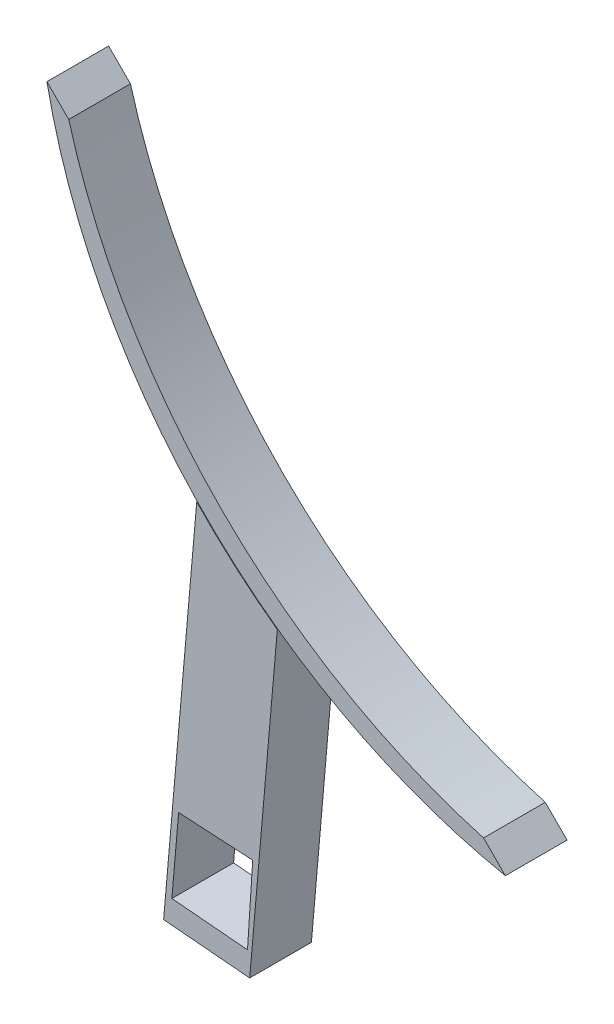
from build123d import *

# Parameters (mm, degrees)
BOSS_EXTRUDE1_DEPTH             = 10
SCALE1_SCALE                    = 0.5
BOSS_EXTRUDE2_REACH             = 46.064
BOSS_EXTRUDE2_END_RADIUS        = 47.489459432
SKETCH4_W                       = 5
SKETCH4_H                       = 7
BOSS_EXTRUDE2_DIRECTION_2_DEPTH = 20
CUT_EXTRUDE1_DEPTH              = 42.005284287


with BuildPart() as part:
    # Sketch1 → Boss-Extrude1 (new body)
    with BuildSketch(Plane.XY):
        with BuildLine():
            Line((40.984301278, -16.277292989), (37.448767372, -12.741759083))
            ThreePointArc((37.448767372, -12.741759083), (-4.964984169, 12.060025443), (-29.766768694, 54.473776984))
            Line((-29.766768694, 54.473776984), (-33.3023026, 58.00931089))
            ThreePointArc((-33.3023026, 58.00931089), (-7.365037029, 9.659972583), (40.984301278, -16.277292989))
        make_face()
    extrude(amount=BOSS_EXTRUDE1_DEPTH)


with BuildPart() as part_1:
    # Scale1: scaled about (-3.035293352, 13.98971626, 5)
    add(part.part.scale(SCALE1_SCALE).moved(Location((-1.517646676, 6.99485813, 2.5))))

    # Boss-Extrude2: up to this cylinder (the profile starts outside it)
    boss_extrude2_end = Plane(origin=(28.379953609, 45.404963221, 5.043467), z_dir=(0, 0, -1)) * Cylinder(BOSS_EXTRUDE2_END_RADIUS, 188.106918865, mode=Mode.PRIVATE)
    # Sketch4 → Boss-Extrude2 (add, up to the surface)
    with BuildSketch(Plane(origin=(7.010218182, 0.680511093, -0.258230649), x_dir=(0, 0, -1), z_dir=(0.08715574274766595, 0.9961946980917449, 0)), mode=Mode.PRIVATE) as boss_extrude2_sk1:
        with Locations((-5.301697823, 10.489820344)):
            Rectangle(SKETCH4_W, SKETCH4_H)
    boss_extrude2_tool1 = extrude(boss_extrude2_sk1.sketch, amount=BOSS_EXTRUDE2_REACH, mode=Mode.PRIVATE) - boss_extrude2_end
    add(boss_extrude2_tool1.solids().sort_by_distance((-3.439685, 1.594759, 5.043467))[0])

    # Sketch4 → Boss-Extrude2 direction 2 (add)
    with BuildSketch(Plane(origin=(7.010218182, 0.680511093, -0.258230649), x_dir=(0, 0, -1), z_dir=(0.08715574274766595, 0.9961946980917449, 0))):
        with Locations((-5.301697823, 10.489820344)):
            Rectangle(SKETCH4_W, SKETCH4_H)
    extrude(amount=-BOSS_EXTRUDE2_DIRECTION_2_DEPTH)

    # Sketch10 → Cut-Extrude1 (cut, through all)
    with BuildSketch(Plane.XY.offset(7.543467174)):
        Polygon((-8.004005245, -16.209052666), (-7.451990048, -9.899490092), (-1.451990048, -10.245322297), (-1.874415312, -16.745322297), align=None)
    extrude(amount=-CUT_EXTRUDE1_DEPTH, mode=Mode.SUBTRACT)


solid = part_1.part
